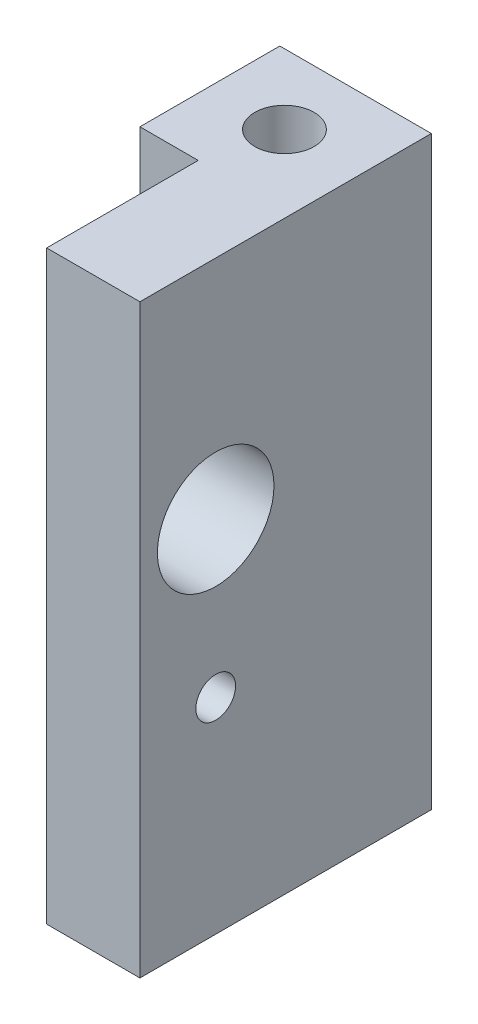
from build123d import *

# Parameters (mm, degrees)
BOSS_EXTRUDE1_DEPTH        = 39.878
F_10_32_TAPPED_HOLE1_D     = 4.0386
F_10_32_TAPPED_HOLE1_DEPTH = 39.878
F_6_32_TAPPED_HOLE1_D      = 2.7051
F_6_32_TAPPED_HOLE1_DEPTH  = 6.35
CUT_EXTRUDE1_REACH         = 12.319
SKETCH10_R                 = 3.96875


with BuildPart() as part:
    # Sketch1 → Boss-Extrude1 (new body)
    with BuildSketch(Plane(origin=(0, 0, 0), x_dir=(1, 0, 0), z_dir=(0, 1, 0))):
        Polygon((0, 0), (-3.96875, 0), (-3.96875, 9.525), (6.35, 9.525), (6.35, -10.31875), (0, -10.31875), align=None)
    extrude(amount=BOSS_EXTRUDE1_DEPTH)

    # #10-32 Tapped Hole1
    with Locations(Plane(origin=(0, 39.878, 0), x_dir=(1, 0, 0), z_dir=(0, 1, 0))):
        with Locations((1.11125, 4.7625)):
            Hole(F_10_32_TAPPED_HOLE1_D / 2, depth=F_10_32_TAPPED_HOLE1_DEPTH)

    # #6-32 Tapped Hole1
    with Locations(Plane.ZY):
        with Locations((5.159375, 13.97254)):
            Hole(F_6_32_TAPPED_HOLE1_D / 2, depth=F_6_32_TAPPED_HOLE1_DEPTH)

    # Sketch10 → Cut-Extrude1 (cut, up to next)
    with BuildSketch(Plane(origin=(6.35, 0, 0), x_dir=(0, 0, -1), z_dir=(1, 0, 0)), mode=Mode.PRIVATE) as cut_extrude1_sk1:
        with Locations((-5.159375, 24.47254)):
            Circle(SKETCH10_R)
    cut_extrude1_tool1 = extrude(cut_extrude1_sk1.sketch, amount=-CUT_EXTRUDE1_REACH, mode=Mode.PRIVATE) & part.part
    add(cut_extrude1_tool1.solids().sort_by_distance((6.35, 24.47254, 5.159375))[0], mode=Mode.SUBTRACT)


solid = part.part
